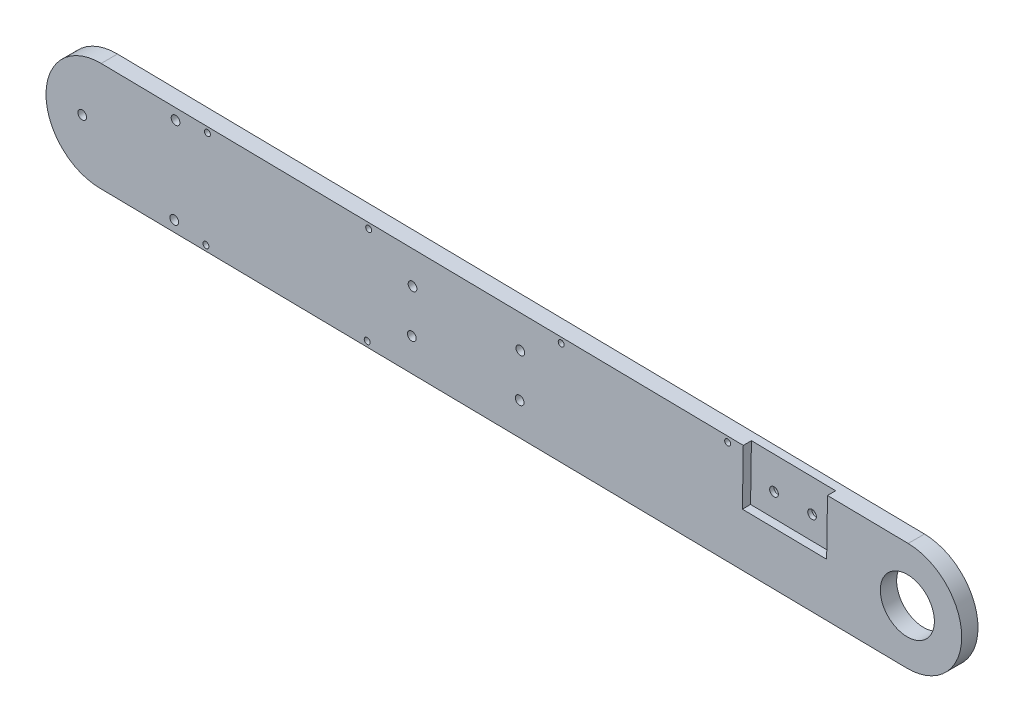
from build123d import *

# Parameters (mm, degrees)
BOSS_EXTRUDE1_DEPTH = 6
SKETCH2_R           = 12.45
BOSS_EXTRUDE2_DEPTH = 5.25
CUT_EXTRUDE2_REACH  = 13.25
SKETCH5_R           = 1.6
SKETCH6_R           = 2.75
CUT_EXTRUDE3_DEPTH  = 3.2
SKETCH7_R           = 2.75
CUT_EXTRUDE4_DEPTH  = 3.2
CUT_EXTRUDE7_REACH  = 8
SKETCH10_R          = 9.95
CUT_EXTRUDE8_REACH  = 13.25
SKETCH11_R          = 1.6
SKETCH12_R          = 2.75
CUT_EXTRUDE9_DEPTH  = 3
CUT_EXTRUDE10_DEPTH = 3
CUT_EXTRUDE11_REACH = 13.25
SKETCH14_R          = 1.6
SKETCH15_R          = 2.75
CUT_EXTRUDE12_DEPTH = 1.5
CUT_EXTRUDE13_REACH = 13.25
SKETCH16_R          = 1.1


with BuildPart() as part:
    # Sketch1 → Boss-Extrude1 (new body)
    with BuildSketch(Plane.XY):
        with BuildLine():
            Line((53.452478751, 19.630204959), (350.418509131, 15.138345609))
            ThreePointArc((350.418509131, 15.138345609), (370.113739503, -5.161848985), (349.813544909, -24.857079358))
            Line((349.813544909, -24.857079358), (52.847514529, -20.365220008))
            ThreePointArc((52.847514529, -20.365220008), (33.152284157, -0.065025413), (53.452478751, 19.630204959))
        make_face()
    extrude(amount=BOSS_EXTRUDE1_DEPTH)

    # Sketch2 → Boss-Extrude2 (add)
    with BuildSketch(Plane(origin=(0, 0, 0), x_dir=(-1, 0, 0), z_dir=(0, 0, -1))):
        with Locations((-53.14999664, -0.367507524)):
            Circle(SKETCH2_R)
    extrude(amount=BOSS_EXTRUDE2_DEPTH)

    # Sketch5 → Cut-Extrude2 (cut, up to next)
    with BuildSketch(Plane.XY.offset(6), mode=Mode.PRIVATE) as cut_extrude2_sk1:
        with Locations((80.82937417, 15.215648985)):
            Circle(SKETCH5_R)
    cut_extrude2_tool1 = extrude(cut_extrude2_sk1.sketch, amount=-CUT_EXTRUDE2_REACH, mode=Mode.PRIVATE) & part.part
    add(cut_extrude2_tool1.solids().sort_by_distance((80.829374, 15.215649, 6))[0], mode=Mode.SUBTRACT)
    # Sketch5 → Cut-Extrude2 (cut, up to next)
    with BuildSketch(Plane.XY.offset(6), mode=Mode.PRIVATE) as cut_extrude2_sk2:
        with Locations((46.471460884, -0.26648909)):
            Circle(SKETCH5_R)
    cut_extrude2_tool2 = extrude(cut_extrude2_sk2.sketch, amount=-CUT_EXTRUDE2_REACH, mode=Mode.PRIVATE) & part.part
    add(cut_extrude2_tool2.solids().sort_by_distance((46.471461, -0.266489, 6))[0], mode=Mode.SUBTRACT)
    # Sketch5 → Cut-Extrude2 (cut, up to next)
    with BuildSketch(Plane.XY.offset(6), mode=Mode.PRIVATE) as cut_extrude2_sk3:
        with Locations((80.345467382, -16.77642084)):
            Circle(SKETCH5_R)
    cut_extrude2_tool3 = extrude(cut_extrude2_sk3.sketch, amount=-CUT_EXTRUDE2_REACH, mode=Mode.PRIVATE) & part.part
    add(cut_extrude2_tool3.solids().sort_by_distance((80.345467, -16.776421, 6))[0], mode=Mode.SUBTRACT)

    # Sketch6 → Cut-Extrude3 (cut)
    with BuildSketch(Plane(origin=(0, 0, 0), x_dir=(-1, 0, 0), z_dir=(0, 0, -1))):
        with Locations((-80.345467382, -16.77642084)):
            Circle(SKETCH6_R)
        with Locations((-80.82937417, 15.215648985)):
            Circle(SKETCH6_R)
    extrude(amount=-CUT_EXTRUDE3_DEPTH, mode=Mode.SUBTRACT)

    # Sketch7 → Cut-Extrude4 (cut)
    with BuildSketch(Plane(origin=(0, 0, -5.25), x_dir=(-1, 0, 0), z_dir=(0, 0, -1))):
        with Locations((-46.471460884, -0.26648909)):
            Circle(SKETCH7_R)
    extrude(amount=-CUT_EXTRUDE4_DEPTH, mode=Mode.SUBTRACT)

    # Sketch10 → Cut-Extrude7 (cut, up to next)
    with BuildSketch(Plane(origin=(0, 0, 0), x_dir=(-1, 0, 0), z_dir=(0, 0, -1)), mode=Mode.PRIVATE) as cut_extrude7_sk1:
        with Locations((-350.11602702, -4.859366874)):
            Circle(SKETCH10_R)
    cut_extrude7_tool1 = extrude(cut_extrude7_sk1.sketch, amount=-CUT_EXTRUDE7_REACH, mode=Mode.PRIVATE) & part.part
    add(cut_extrude7_tool1.solids().sort_by_distance((350.116027, -4.859367, 0))[0], mode=Mode.SUBTRACT)

    # Sketch11 → Cut-Extrude8 (cut, up to next)
    with BuildSketch(Plane.XY.offset(6), mode=Mode.PRIVATE) as cut_extrude8_sk1:
        with Locations((207.693855596, 5.295802586)):
            Circle(SKETCH11_R)
    cut_extrude8_tool1 = extrude(cut_extrude8_sk1.sketch, amount=-CUT_EXTRUDE8_REACH, mode=Mode.PRIVATE) & part.part
    add(cut_extrude8_tool1.solids().sort_by_distance((207.693856, 5.295803, 6))[0], mode=Mode.SUBTRACT)
    # Sketch11 → Cut-Extrude8 (cut, up to next)
    with BuildSketch(Plane.XY.offset(6), mode=Mode.PRIVATE) as cut_extrude8_sk2:
        with Locations((207.451869907, -10.702367401)):
            Circle(SKETCH11_R)
    cut_extrude8_tool2 = extrude(cut_extrude8_sk2.sketch, amount=-CUT_EXTRUDE8_REACH, mode=Mode.PRIVATE) & part.part
    add(cut_extrude8_tool2.solids().sort_by_distance((207.45187, -10.702367, 6))[0], mode=Mode.SUBTRACT)
    # Sketch11 → Cut-Extrude8 (cut, up to next)
    with BuildSketch(Plane.XY.offset(6), mode=Mode.PRIVATE) as cut_extrude8_sk3:
        with Locations((168.025770935, 5.895815512)):
            Circle(SKETCH11_R)
    cut_extrude8_tool3 = extrude(cut_extrude8_sk3.sketch, amount=-CUT_EXTRUDE8_REACH, mode=Mode.PRIVATE) & part.part
    add(cut_extrude8_tool3.solids().sort_by_distance((168.025771, 5.895816, 6))[0], mode=Mode.SUBTRACT)
    # Sketch11 → Cut-Extrude8 (cut, up to next)
    with BuildSketch(Plane.XY.offset(6), mode=Mode.PRIVATE) as cut_extrude8_sk4:
        with Locations((167.783785246, -10.102354474)):
            Circle(SKETCH11_R)
    cut_extrude8_tool4 = extrude(cut_extrude8_sk4.sketch, amount=-CUT_EXTRUDE8_REACH, mode=Mode.PRIVATE) & part.part
    add(cut_extrude8_tool4.solids().sort_by_distance((167.783785, -10.102354, 6))[0], mode=Mode.SUBTRACT)

    # Sketch12 → Cut-Extrude9 (cut)
    with BuildSketch(Plane(origin=(0, 0, 0), x_dir=(-1, 0, 0), z_dir=(0, 0, -1))):
        with Locations((-207.451869907, -10.702367401)):
            Circle(SKETCH12_R)
        with Locations((-207.693855596, 5.295802586)):
            Circle(SKETCH12_R)
        with Locations((-168.025770935, 5.895815512)):
            Circle(SKETCH12_R)
        with Locations((-167.783785246, -10.102354474)):
            Circle(SKETCH12_R)
    extrude(amount=-CUT_EXTRUDE9_DEPTH, mode=Mode.SUBTRACT)

    # Sketch13 → Cut-Extrude10 (cut)
    with BuildSketch(Plane.XY.offset(6)):
        Polygon((289.732546516, 16.056271502), (289.422502353, -4.441383793), (320.418956702, -4.910231066), (320.729000866, 15.58742423), align=None)
    extrude(amount=-CUT_EXTRUDE10_DEPTH, mode=Mode.SUBTRACT)

    # Sketch14 → Cut-Extrude11 (cut, up to next)
    with BuildSketch(Plane.XY.offset(6), mode=Mode.PRIVATE) as cut_extrude11_sk1:
        with Locations((312.048483794, 3.717351637)):
            Circle(SKETCH14_R)
    cut_extrude11_tool1 = extrude(cut_extrude11_sk1.sketch, amount=-CUT_EXTRUDE11_REACH, mode=Mode.PRIVATE) & part.part
    add(cut_extrude11_tool1.solids().sort_by_distance((312.048484, 3.717352, 6))[0], mode=Mode.SUBTRACT)
    # Sketch14 → Cut-Extrude11 (cut, up to next)
    with BuildSketch(Plane.XY.offset(6), mode=Mode.PRIVATE) as cut_extrude11_sk2:
        with Locations((298.050085055, 3.929089115)):
            Circle(SKETCH14_R)
    cut_extrude11_tool2 = extrude(cut_extrude11_sk2.sketch, amount=-CUT_EXTRUDE11_REACH, mode=Mode.PRIVATE) & part.part
    add(cut_extrude11_tool2.solids().sort_by_distance((298.050085, 3.929089, 6))[0], mode=Mode.SUBTRACT)

    # Sketch15 → Cut-Extrude12 (cut)
    with BuildSketch(Plane(origin=(0, 0, 0), x_dir=(-1, 0, 0), z_dir=(0, 0, -1))):
        with Locations((-298.050085055, 3.929089115)):
            Circle(SKETCH15_R)
        with Locations((-312.048483794, 3.717351637)):
            Circle(SKETCH15_R)
    extrude(amount=-CUT_EXTRUDE12_DEPTH, mode=Mode.SUBTRACT)

    # Sketch16 → Cut-Extrude13 (cut, up to next)
    with BuildSketch(Plane.XY.offset(6), mode=Mode.PRIVATE) as cut_extrude13_sk1:
        with Locations((92.548117071, 17.038621984)):
            Circle(SKETCH16_R)
    cut_extrude13_tool1 = extrude(cut_extrude13_sk1.sketch, amount=-CUT_EXTRUDE13_REACH, mode=Mode.PRIVATE) & part.part
    add(cut_extrude13_tool1.solids().sort_by_distance((92.548117, 17.038622, 6))[0], mode=Mode.SUBTRACT)
    # Sketch16 → Cut-Extrude13 (cut, up to next)
    with BuildSketch(Plane.XY.offset(6), mode=Mode.PRIVATE) as cut_extrude13_sk2:
        with Locations((92.003649271, -18.957260486)):
            Circle(SKETCH16_R)
    cut_extrude13_tool2 = extrude(cut_extrude13_sk2.sketch, amount=-CUT_EXTRUDE13_REACH, mode=Mode.PRIVATE) & part.part
    add(cut_extrude13_tool2.solids().sort_by_distance((92.003649, -18.95726, 6))[0], mode=Mode.SUBTRACT)
    # Sketch16 → Cut-Extrude13 (cut, up to next)
    with BuildSketch(Plane.XY.offset(6), mode=Mode.PRIVATE) as cut_extrude13_sk3:
        with Locations((151.905473082, 16.140792376)):
            Circle(SKETCH16_R)
    cut_extrude13_tool3 = extrude(cut_extrude13_sk3.sketch, amount=-CUT_EXTRUDE13_REACH, mode=Mode.PRIVATE) & part.part
    add(cut_extrude13_tool3.solids().sort_by_distance((151.905473, 16.140792, 6))[0], mode=Mode.SUBTRACT)
    # Sketch16 → Cut-Extrude13 (cut, up to next)
    with BuildSketch(Plane.XY.offset(6), mode=Mode.PRIVATE) as cut_extrude13_sk4:
        with Locations((151.361005282, -19.855090094)):
            Circle(SKETCH16_R)
    cut_extrude13_tool4 = extrude(cut_extrude13_sk4.sketch, amount=-CUT_EXTRUDE13_REACH, mode=Mode.PRIVATE) & part.part
    add(cut_extrude13_tool4.solids().sort_by_distance((151.361005, -19.85509, 6))[0], mode=Mode.SUBTRACT)
    # Sketch16 → Cut-Extrude13 (cut, up to next)
    with BuildSketch(Plane.XY.offset(6), mode=Mode.PRIVATE) as cut_extrude13_sk5:
        with Locations((222.744414799, 15.069294191)):
            Circle(SKETCH16_R)
    cut_extrude13_tool5 = extrude(cut_extrude13_sk5.sketch, amount=-CUT_EXTRUDE13_REACH, mode=Mode.PRIVATE) & part.part
    add(cut_extrude13_tool5.solids().sort_by_distance((222.744415, 15.069294, 6))[0], mode=Mode.SUBTRACT)
    # Sketch16 → Cut-Extrude13 (cut, up to next)
    with BuildSketch(Plane.XY.offset(6), mode=Mode.PRIVATE) as cut_extrude13_sk6:
        with Locations((283.996308166, 14.142808123)):
            Circle(SKETCH16_R)
    cut_extrude13_tool6 = extrude(cut_extrude13_sk6.sketch, amount=-CUT_EXTRUDE13_REACH, mode=Mode.PRIVATE) & part.part
    add(cut_extrude13_tool6.solids().sort_by_distance((283.996308, 14.142808, 6))[0], mode=Mode.SUBTRACT)


solid = part.part
